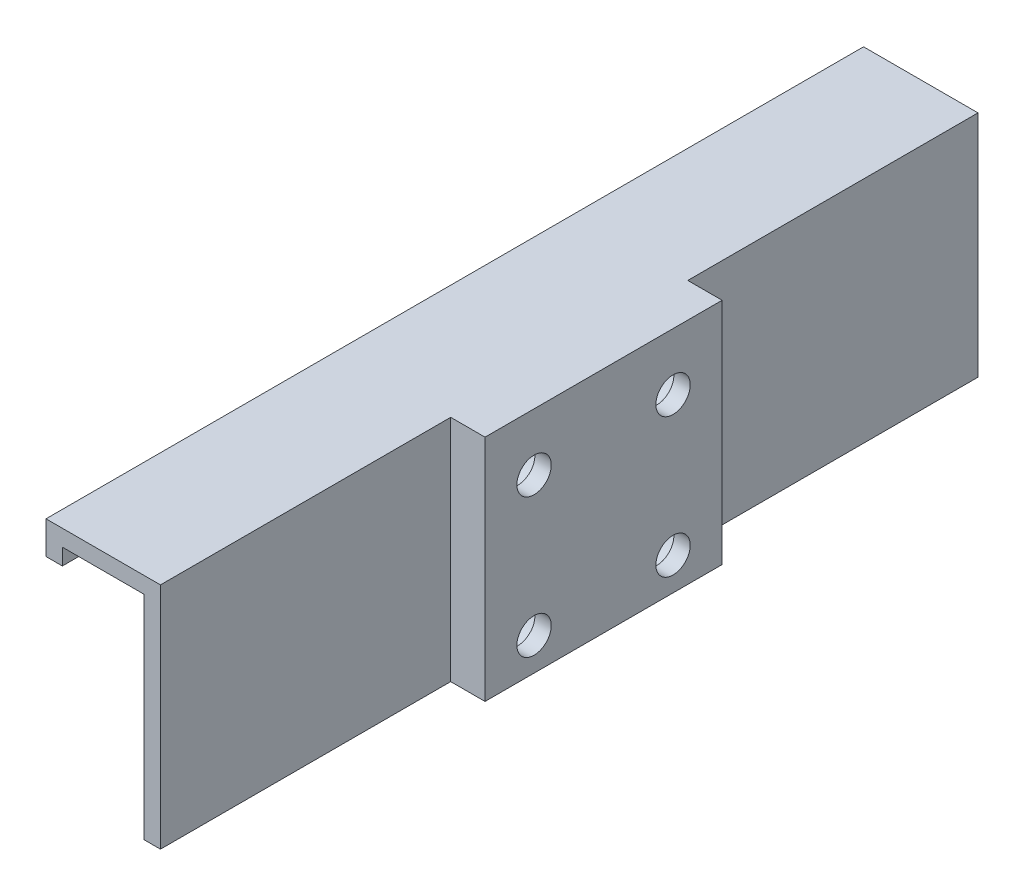
from build123d import *

# Parameters (mm, degrees)
SKETCH1_W           = 100
SKETCH1_H           = 26
BOSS_EXTRUDE1_DEPTH = 2
BOSS_EXTRUDE2_DEPTH = 100
SKETCH3_W           = 25
SKETCH3_H           = 28
BOSS_EXTRUDE3_DEPTH = 4
SKETCH4_R           = 2.1
CUT_EXTRUDE1_DEPTH  = 106.39449701
MOVE_FACE1_BY       = 2
MOVE_FACE1_2_BY     = 2
SKETCH5_R           = 3.6
CUT_EXTRUDE2_DEPTH  = 4.2
MOVE_FACE2_BY       = 4
MOVE_FACE3_BY       = 3.8


with BuildPart() as part:
    # Sketch1 → Boss-Extrude1 (new body)
    with BuildSketch(Plane(origin=(0, 0, 0), x_dir=(0, 0, -1), z_dir=(1, 0, 0))):
        with Locations((50, 13)):
            Rectangle(SKETCH1_W, SKETCH1_H)
    extrude(amount=BOSS_EXTRUDE1_DEPTH)

    # Sketch2 → Boss-Extrude2 (add)
    with BuildSketch(Plane.XY):
        Polygon((2, 26), (2, 28), (-12, 28), (-12, 24), (-10, 24), (-10, 26), align=None)
    extrude(amount=-BOSS_EXTRUDE2_DEPTH)

    # Sketch3 → Boss-Extrude3 (add)
    with BuildSketch(Plane(origin=(2, 0, 0), x_dir=(0, 0, -1), z_dir=(1, 0, 0))):
        with Locations((50, 14)):
            Rectangle(SKETCH3_W, SKETCH3_H)
    extrude(amount=BOSS_EXTRUDE3_DEPTH)

    # Sketch4 → Cut-Extrude1 (cut, through all)
    with BuildSketch(Plane(origin=(6, 0, 0), x_dir=(0, 0, -1), z_dir=(1, 0, 0))):
        with Locations((41.5, 21)):
            Circle(SKETCH4_R)
        with Locations((58.5, 21)):
            Circle(SKETCH4_R)
        with Locations((58.5, 4)):
            Circle(SKETCH4_R)
        with Locations((41.5, 4)):
            Circle(SKETCH4_R)
    extrude(amount=-CUT_EXTRUDE1_DEPTH, mode=Mode.SUBTRACT)

    # Move Face1: a face moved outward by 2.0
    extrude(part.faces().sort_by_distance((4, 14, -37.5))[0], amount=MOVE_FACE1_BY, dir=(0, 0, 1))

    # Move Face1 2: a face moved outward by 2.0
    extrude(part.faces().sort_by_distance((4, 14, -62.5))[0], amount=MOVE_FACE1_2_BY, dir=(0, 0, -1))

    # Sketch5 → Cut-Extrude2 (cut)
    with BuildSketch(Plane.ZY):
        with Locations((-58.5, 21)):
            Circle(SKETCH5_R)
        with Locations((-41.5, 21)):
            Circle(SKETCH5_R)
        with Locations((-41.5, 4)):
            Circle(SKETCH5_R)
        with Locations((-58.5, 4)):
            Circle(SKETCH5_R)
    extrude(amount=-CUT_EXTRUDE2_DEPTH, mode=Mode.SUBTRACT)

    # Move Face2: a face moved outward by 4.0
    extrude(part.faces().sort_by_distance((6, 14.109871115, -50))[0], amount=MOVE_FACE2_BY, dir=(1, 0, 0))

    # Move Face3: a face moved inward by 3.8
    extrude(part.faces().sort_by_distance((10, 14.109871115, -50))[0], amount=MOVE_FACE3_BY, dir=(-1, 0, 0), mode=Mode.SUBTRACT)


solid = part.part
